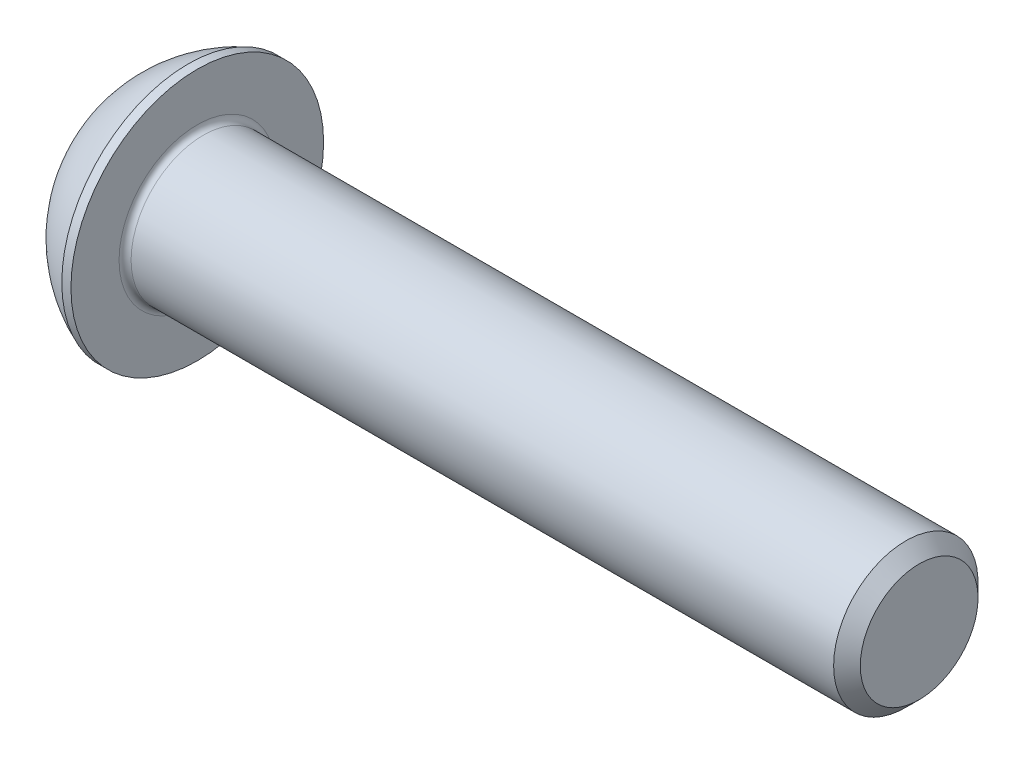
from build123d import *

# Parameters (mm, degrees)
FILLET1_R   = 0.25
HEX_2_DEPTH = 2.08


with BuildPart() as part:
    # BodySke → BaseBody (revolve)
    with BuildSketch(Plane.XY):
        with BuildLine():
            Line((33.3, 0), (33.3, 2.4455))
            Line((33.3, 2.4455), (32.7455, 3))
            Line((32.7455, 3), (3.3, 3))
            Line((3.3, 3), (3.3, 5.25))
            Line((3.3, 5.25), (2.92, 5.25))
            ThreePointArc((2.92, 5.25), (1.224500646, 4.199464996), (0, 2.625))
            Line((0, 2.625), (0, 0))
            Line((0, 0), (33.3, 0))
        make_face()
    revolve(axis=Axis((0, 0, 0), (1, 0, 0)))

    # Fillet1
    fillet1_edges = [part.edges().sort_by_distance(p)[0] for p in [
        (3.3, -3, 0),
    ]]
    fillet(fillet1_edges, radius=FILLET1_R)

    # Sketch2 → PreBroach (revolve, cut)
    with BuildSketch(Plane.XY):
        Polygon((0, 2), (2.08, 2), (3.234700538, 0), (0, 0), align=None)
    revolve(axis=Axis((0, 0, 0), (1, 0, 0)), mode=Mode.SUBTRACT)

    # Sketch3 → Hex 2 (cut)
    with BuildSketch(Plane(origin=(0, 0, 0), x_dir=(0, 0, -1), z_dir=(1, 0, 0))):
        Polygon((-2, -1.154700538), (-2, 1.154700538), (0, 2.309401077), (2, 1.154700538), (2, -1.154700538), (0, -2.309401077), align=None)
    extrude(amount=HEX_2_DEPTH, mode=Mode.SUBTRACT)


solid = part.part
